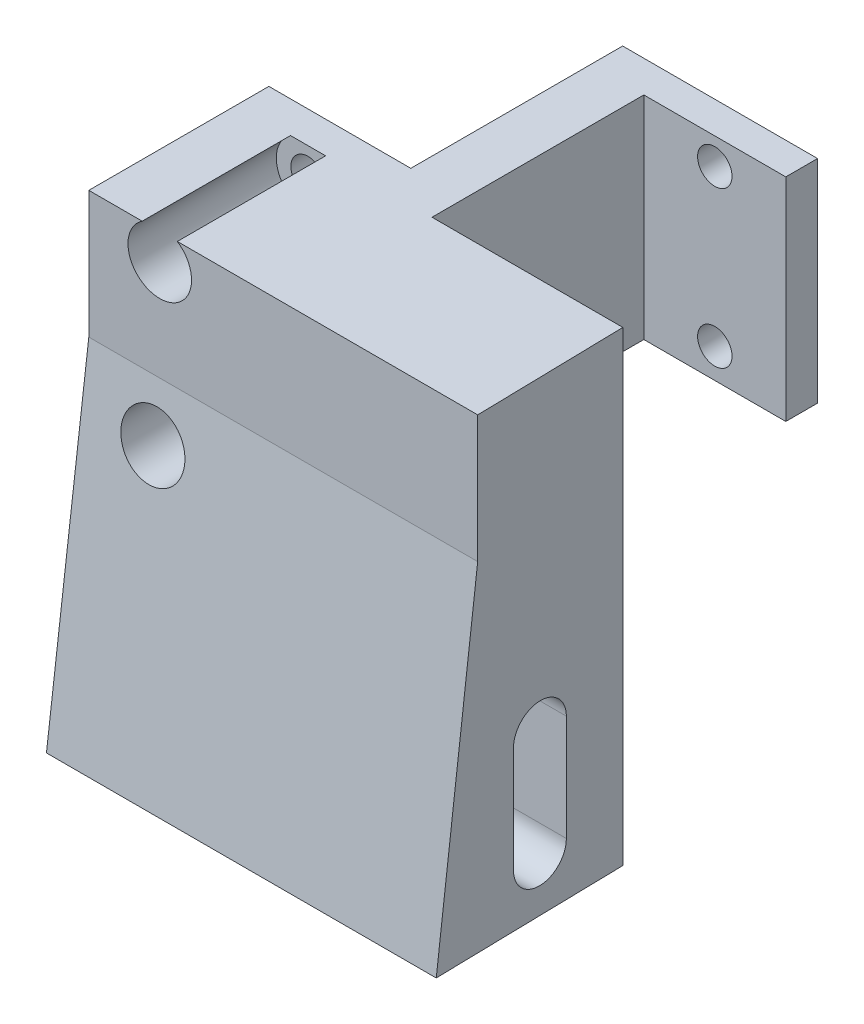
from build123d import *

# Parameters (mm, degrees)
BOSS_EXTRUDE1_DEPTH              = 20
CUT_EXTRUDE1_START               = -4
SKETCH2_R                        = 1.625
CUT_EXTRUDE1_DEPTH               = 25
BOSS_EXTRUDE2_DEPTH              = 36.8
CUT_EXTRUDE2_DEPTH               = 45
CUT_EXTRUDE3_REACH               = 43.8
CUT_EXTRUDE3_OFFSET_FROM_SURFACE = 5
SKETCH6_R                        = 3
CUT_EXTRUDE4_DEPTH               = 19


with BuildPart() as part:
    # Sketch1 → Boss-Extrude1 (new body)
    with BuildSketch(Plane(origin=(0, 0, 0), x_dir=(1, 0, 0), z_dir=(0, 1, 0))):
        Polygon((0, 0), (18.4, 0), (18.4, 20), (31.8, 20), (31.8, 23), (13.4, 23), (13.4, 3), (0, 3), align=None)
    extrude(amount=BOSS_EXTRUDE1_DEPTH)

    # Sketch2 → Cut-Extrude1 (cut)
    with BuildSketch(Plane.XY.offset(-20).offset(CUT_EXTRUDE1_START)):
        with Locations((25.1, 2.8)):
            Circle(SKETCH2_R)
        with Locations((25.1, 17.5)):
            Circle(SKETCH2_R)
    cut_extrude1 = extrude(amount=CUT_EXTRUDE1_DEPTH, mode=Mode.SUBTRACT)

    # Mirror1: Cut-Extrude1 across plane
    add(cut_extrude1.mirror(Plane.ZY.offset(-15.9)), mode=Mode.SUBTRACT)

    # Sketch3 → Boss-Extrude2 (add)
    with BuildSketch(Plane.ZY):
        Polygon((0, 0), (0, -24), (18, -24), (14, 8), (14, 20), (0, 20), align=None)
        with BuildLine():
            Line((10.55, -9), (10.55, -19))
            ThreePointArc((10.55, -19), (8, -21.55), (5.45, -19))
            Line((5.45, -19), (5.45, -9))
            ThreePointArc((5.45, -9), (8, -6.45), (10.55, -9))
        make_face(mode=Mode.SUBTRACT)
    extrude(amount=-BOSS_EXTRUDE2_DEPTH)

    # Sketch4 → Cut-Extrude2 (cut, through all)
    with BuildSketch(Plane.XZ.offset(24)):
        Polygon((36.8, 18), (36.416667761, 0), (36.8, 0), align=None)
    extrude(amount=-CUT_EXTRUDE2_DEPTH, mode=Mode.SUBTRACT)

    # Cut-Extrude3: up to this face of the body (flat: up to its plane, moved by the offset)
    cut_extrude3_end = Plane(part.part.faces().sort_by_distance((36.581905222, -1.783418912, 7.75899858))[0]).offset(-CUT_EXTRUDE3_OFFSET_FROM_SURFACE)
    # Sketch5 → Cut-Extrude3 (cut, up to the picked face)
    with BuildSketch(Plane.ZY, mode=Mode.PRIVATE) as cut_extrude3_sk1:
        with BuildLine():
            Line((14, -9), (14, -24))
            Line((14, -24), (2, -24))
            Line((2, -24), (2, -9))
            ThreePointArc((2, -9), (8, -3), (14, -9))
        make_face()
    cut_extrude3_tool1 = split(extrude(cut_extrude3_sk1.sketch, amount=-CUT_EXTRUDE3_REACH, mode=Mode.PRIVATE), bisect_by=cut_extrude3_end, keep=Keep.BOTH, mode=Mode.PRIVATE)
    add(cut_extrude3_tool1.solids().sort_by_distance((0, -14.098317, 8))[0], mode=Mode.SUBTRACT)

    # Sketch6 → Cut-Extrude4 (cut, through all)
    with BuildSketch(Plane(origin=(0, 0, 0), x_dir=(-1, 0, 0), z_dir=(0, 0, -1))):
        with Locations((-6.7, 2.8)):
            Circle(SKETCH6_R)
        with Locations((-6.7, 17.5)):
            Circle(SKETCH6_R)
    extrude(amount=-CUT_EXTRUDE4_DEPTH, mode=Mode.SUBTRACT)


solid = part.part
